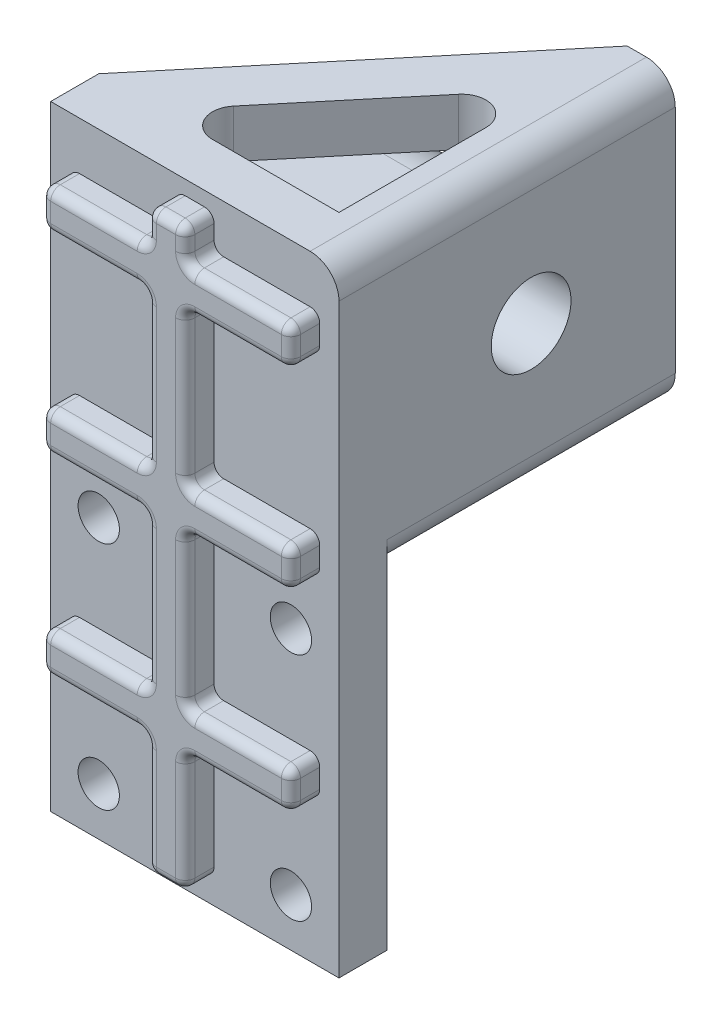
from build123d import *

# Parameters (mm, degrees)
SKETCH3_W           = 30
SKETCH3_H           = 34
SKETCH3_R           = 2.15
BOSS_EXTRUDE1_DEPTH = 5
SKETCH5_W           = 5
SKETCH5_H           = 30
SKETCH5_W_2         = 25
BOSS_EXTRUDE4_DEPTH = 5
SKETCH6_W           = 5
SKETCH6_H           = 30
BOSS_EXTRUDE5_DEPTH = 30
SKETCH7_W           = 26
SKETCH7_H           = 4
SKETCH7_W_2         = 4
SKETCH7_H_2         = 60
BOSS_EXTRUDE6_DEPTH = 3
FILLET1_R           = 1
BOSS_EXTRUDE7_DEPTH = 5
BOSS_EXTRUDE8_DEPTH = 5
FILLET2_R           = 2.5
SKETCH11_R          = 4.15
CUT_EXTRUDE1_DEPTH  = 6
FILLET3_R           = 3
FILLET4_R           = 3
SKETCH13_R          = 4.15
BOSS_EXTRUDE9_DEPTH = 20
FILLET5_R           = 2


with BuildPart() as part:
    # Sketch3 → Boss-Extrude1 (new body)
    with BuildSketch(Plane.XY):
        with Locations((15, -17)):
            Rectangle(SKETCH3_W, SKETCH3_H)
        with Locations((5, -5)):
            Circle(SKETCH3_R, mode=Mode.SUBTRACT)
        with Locations((25, -5)):
            Circle(SKETCH3_R, mode=Mode.SUBTRACT)
        with Locations((5, -29)):
            Circle(SKETCH3_R, mode=Mode.SUBTRACT)
        with Locations((25, -29)):
            Circle(SKETCH3_R, mode=Mode.SUBTRACT)
    extrude(amount=BOSS_EXTRUDE1_DEPTH)

    # Sketch5 → Boss-Extrude4 (add)
    with BuildSketch(Plane(origin=(0, 0, 0), x_dir=(-1, 0, 0), z_dir=(0, 0, -1))):
        with Locations((-27.5, 15)):
            Rectangle(SKETCH5_W, SKETCH5_H)
        with Locations((-12.5, 15)):
            Rectangle(SKETCH5_W_2, SKETCH5_H)
    extrude(amount=-BOSS_EXTRUDE4_DEPTH)

    # Sketch6 → Boss-Extrude5 (add)
    with BuildSketch(Plane(origin=(0, 0, 0), x_dir=(-1, 0, 0), z_dir=(0, 0, -1))):
        with Locations((-27.5, 15)):
            Rectangle(SKETCH6_W, SKETCH6_H)
    extrude(amount=BOSS_EXTRUDE5_DEPTH)

    # Sketch7 → Boss-Extrude6 (add)
    with BuildSketch(Plane.XY.offset(5)):
        with Locations((15, 3)):
            Rectangle(SKETCH7_W, SKETCH7_H)
        with Locations((15, -1.5)):
            Rectangle(SKETCH7_W_2, SKETCH7_H_2)
        with Locations((15, -17)):
            Rectangle(SKETCH7_W, SKETCH7_H)
        with Locations((15, 23)):
            Rectangle(SKETCH7_W, SKETCH7_H)
    extrude(amount=BOSS_EXTRUDE6_DEPTH)

    # Fillet1
    fillet1_edges = [part.edges().sort_by_distance(p)[0] for p in [
        (17, 26.75, 8),
        (17, 25, 6.5),
        (17, 13, 8),
        (17, 5, 6.5),
        (17, -7, 8),
        (17, -15, 6.5),
        (17, -25.25, 8),
        (17, -31.5, 6.5),
        (13, -31.5, 6.5),
        (13, 28.5, 6.5),
        (13, 21, 6.5),
        (13, 1, 6.5),
        (13, -19, 6.5),
        (15, 28.5, 8),
        (17, 28.5, 6.5),
        (28, 23, 8),
        (28, 21, 6.5),
        (22.5, 25, 8),
        (28, 25, 6.5),
        (17, 21, 6.5),
        (13, 26.75, 8),
        (2, 23, 8),
        (7.5, 21, 8),
        (13, 13, 8),
        (2, 3, 8),
        (7.5, 1, 8),
        (13, -7, 8),
        (2, -17, 8),
        (7.5, -19, 8),
        (13, -25.25, 8),
        (15, -31.5, 8),
        (22.5, -19, 8),
        (22.5, 1, 8),
        (22.5, 21, 8),
        (28, 3, 8),
        (28, 1, 6.5),
        (22.5, 5, 8),
        (28, 5, 6.5),
        (17, 1, 6.5),
        (28, -17, 8),
        (28, -19, 6.5),
        (22.5, -15, 8),
        (28, -15, 6.5),
        (17, -19, 6.5),
        (7.5, 25, 8),
        (13, 25, 6.5),
        (2, 25, 6.5),
        (2, 21, 6.5),
        (7.5, 5, 8),
        (13, 5, 6.5),
        (2, 5, 6.5),
        (2, 1, 6.5),
        (7.5, -15, 8),
        (13, -15, 6.5),
        (2, -15, 6.5),
        (2, -19, 6.5),
    ]]
    fillet(fillet1_edges, radius=FILLET1_R)

    # Sketch9 → Boss-Extrude7 (add)
    with BuildSketch(Plane(origin=(0, 30, 0), x_dir=(1, 0, 0), z_dir=(0, 1, 0))):
        Polygon((25, 22.189750324), (6.508541397, 0), (0, 0), (25, 30), align=None)
    extrude(amount=-BOSS_EXTRUDE7_DEPTH)

    # Sketch10 → Boss-Extrude8 (add)
    with BuildSketch(Plane.XZ):
        Polygon((25, -30), (25, -22.189750324), (6.508541397, 0), (0, 0), align=None)
    extrude(amount=-BOSS_EXTRUDE8_DEPTH)

    # Fillet2
    fillet2_edges = [part.edges().sort_by_distance(p)[0] for p in [
        (25, 27.5, -22.189750324),
        (6.508541397, 27.5, 0),
        (6.508541397, 2.5, 0),
        (25, 2.5, -22.189750324),
    ]]
    fillet(fillet2_edges, radius=FILLET2_R)

    # Sketch11 → Cut-Extrude1 (cut, through all)
    with BuildSketch(Plane.ZY.offset(-25)):
        with Locations((-15, 15)):
            Circle(SKETCH11_R)
    extrude(amount=-CUT_EXTRUDE1_DEPTH, mode=Mode.SUBTRACT)

    # Fillet3
    fillet3_edges = [part.edges().sort_by_distance(p)[0] for p in [
        (30, 30, -12.5),
    ]]
    fillet(fillet3_edges, radius=FILLET3_R)

    # Fillet4
    fillet4_edges = [part.edges().sort_by_distance(p)[0] for p in [
        (30, 0, -15),
    ]]
    fillet(fillet4_edges, radius=FILLET4_R)

    # Sketch13 → Boss-Extrude9 (add)
    with BuildSketch(Plane.ZY.offset(-25)):
        with BuildLine():
            Line((0, 22.6), (-15, 22.6))
            ThreePointArc((-15, 22.6), (-22.6, 15), (-15, 7.4))
            Line((-15, 7.4), (0, 7.4))
            Line((0, 7.4), (0, 22.6))
        make_face()
        with Locations((-15, 15)):
            Circle(SKETCH13_R, mode=Mode.SUBTRACT)
    extrude(amount=BOSS_EXTRUDE9_DEPTH)

    # Fillet5
    fillet5_edges = [part.edges().sort_by_distance(p)[0] for p in [
        (15, 22.6, 0),
        (15, 7.4, 0),
        (5, 15, 0),
    ]]
    fillet(fillet5_edges, radius=FILLET5_R)


solid = part.part
